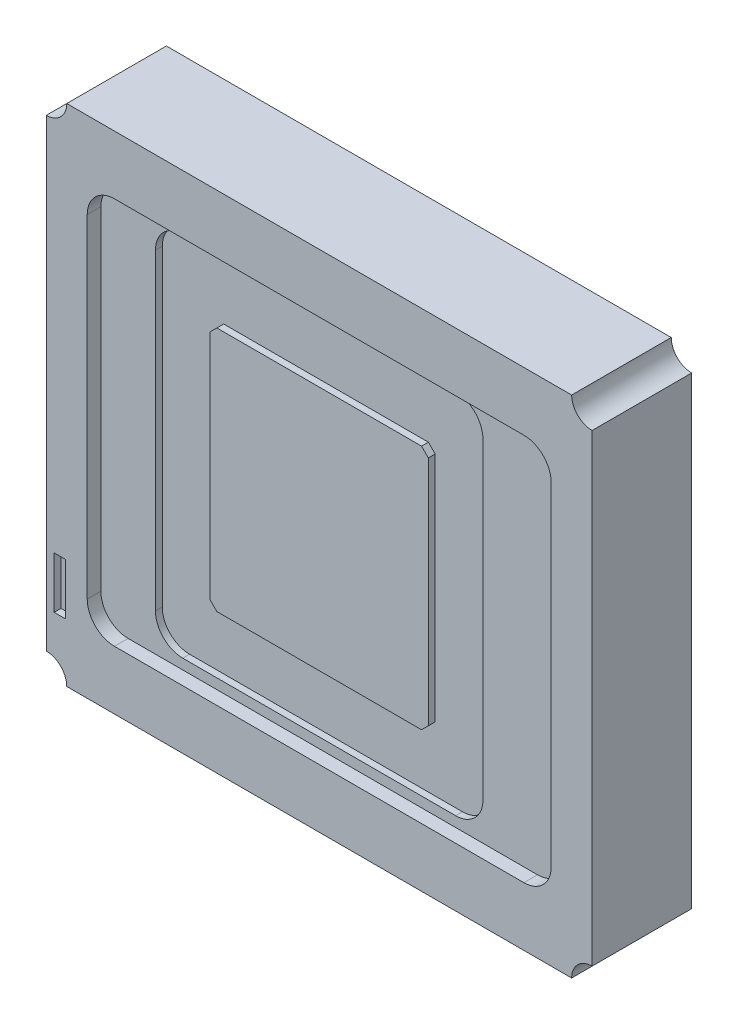
from build123d import *

# Parameters (mm, degrees)
SKETCH1_W            = 4
SKETCH1_H            = 3.7
BOSS_EXTRUDE1_DEPTH  = 0.73
CUT_EXTRUDE1_DEPTH   = 0.73
MIRROR2_COPY_1_DEPTH = 0.73
SKETCH3_W            = 3.4
SKETCH3_H            = 2.84
CUT_EXTRUDE2_DEPTH   = 0.1
FILLET1_R            = 0.2
SKETCH4_W            = 0.083030479
SKETCH4_H            = 0.377411269
CUT_EXTRUDE3_DEPTH   = 0.05
SKETCH6_W            = 2.4
SKETCH6_H            = 2.69
CUT_EXTRUDE4_DEPTH   = 0.05
FILLET2_R            = 0.2
SKETCH7_W            = 1.6
SKETCH7_H            = 1.8
BOSS_EXTRUDE2_DEPTH  = 0.05
CHAMFER1_SIZE        = 0.05


with BuildPart() as part:
    # Sketch1 → Boss-Extrude1 (new body)
    with BuildSketch(Plane.XY):
        with Locations((2, 1.85)):
            Rectangle(SKETCH1_W, SKETCH1_H)
    extrude(amount=BOSS_EXTRUDE1_DEPTH)

    # Sketch2 → Cut-Extrude1 (cut)
    with BuildSketch(Plane.XY.offset(0.73)):
        with BuildLine():
            Line((0.15, 3.7), (0, 3.7))
            Line((0, 3.7), (0, 3.55))
            ThreePointArc((0, 3.55), (0.106066017, 3.593933983), (0.15, 3.7))
        make_face()
    cut_extrude1 = extrude(amount=-CUT_EXTRUDE1_DEPTH, mode=Mode.SUBTRACT)

    # Mirror1: Cut-Extrude1 across plane
    add(cut_extrude1.mirror(Plane(origin=(0, 1.85, 0), x_dir=(0, 0, 1), z_dir=(0, -1, 0))), mode=Mode.SUBTRACT)

    # Mirror2: Cut-Extrude1 across plane
    add(cut_extrude1.mirror(Plane.ZY.offset(-2)), mode=Mode.SUBTRACT)

    # Mirror2 copy 1 sketch → Mirror2 copy 1 (cut)
    with BuildSketch(Plane(origin=(4, 3.7, 0.73), x_dir=(-1, 0, 0), z_dir=(0, 0, 1))):
        with BuildLine():
            Line((0.15, 3.7), (0, 3.7))
            Line((0, 3.7), (0, 3.55))
            ThreePointArc((0, 3.55), (0.106066017, 3.593933983), (0.15, 3.7))
        make_face()
    extrude(amount=-MIRROR2_COPY_1_DEPTH, mode=Mode.SUBTRACT)

    # Sketch3 → Cut-Extrude2 (cut)
    with BuildSketch(Plane.XY.offset(0.73)):
        with Locations((2, 1.85)):
            Rectangle(SKETCH3_W, SKETCH3_H)
    extrude(amount=-CUT_EXTRUDE2_DEPTH, mode=Mode.SUBTRACT)

    # Fillet1
    fillet1_edges = [part.edges().sort_by_distance(p)[0] for p in [
        (0.3, 0.43, 0.68),
        (0.3, 3.27, 0.68),
        (3.7, 3.27, 0.68),
        (3.7, 0.43, 0.68),
    ]]
    fillet(fillet1_edges, radius=FILLET1_R)

    # Sketch4 → Cut-Extrude3 (cut)
    with BuildSketch(Plane.XY.offset(0.73)):
        with Locations((0.099459458, 0.613340546)):
            Rectangle(SKETCH4_W, SKETCH4_H)
    extrude(amount=-CUT_EXTRUDE3_DEPTH, mode=Mode.SUBTRACT)

    # Sketch6 → Cut-Extrude4 (cut)
    with BuildSketch(Plane.XY.offset(0.63)):
        with Locations((1.9, 1.85)):
            Rectangle(SKETCH6_W, SKETCH6_H)
    extrude(amount=-CUT_EXTRUDE4_DEPTH, mode=Mode.SUBTRACT)

    # Fillet2
    fillet2_edges = [part.edges().sort_by_distance(p)[0] for p in [
        (0.7, 0.505, 0.605),
        (0.7, 3.195, 0.605),
        (3.1, 3.195, 0.605),
        (3.1, 0.505, 0.605),
    ]]
    fillet(fillet2_edges, radius=FILLET2_R)

    # Sketch7 → Boss-Extrude2 (add)
    with BuildSketch(Plane.XY.offset(0.58)):
        with Locations((1.9, 1.825640605)):
            Rectangle(SKETCH7_W, SKETCH7_H)
    extrude(amount=BOSS_EXTRUDE2_DEPTH)

    # Chamfer1
    chamfer1_edges = [part.edges().sort_by_distance(p)[0] for p in [
        (1.1, 2.725640605, 0.605),
        (1.1, 0.925640605, 0.605),
        (2.7, 0.925640605, 0.605),
        (2.7, 2.725640605, 0.605),
    ]]
    chamfer(chamfer1_edges, length=CHAMFER1_SIZE)


solid = part.part
